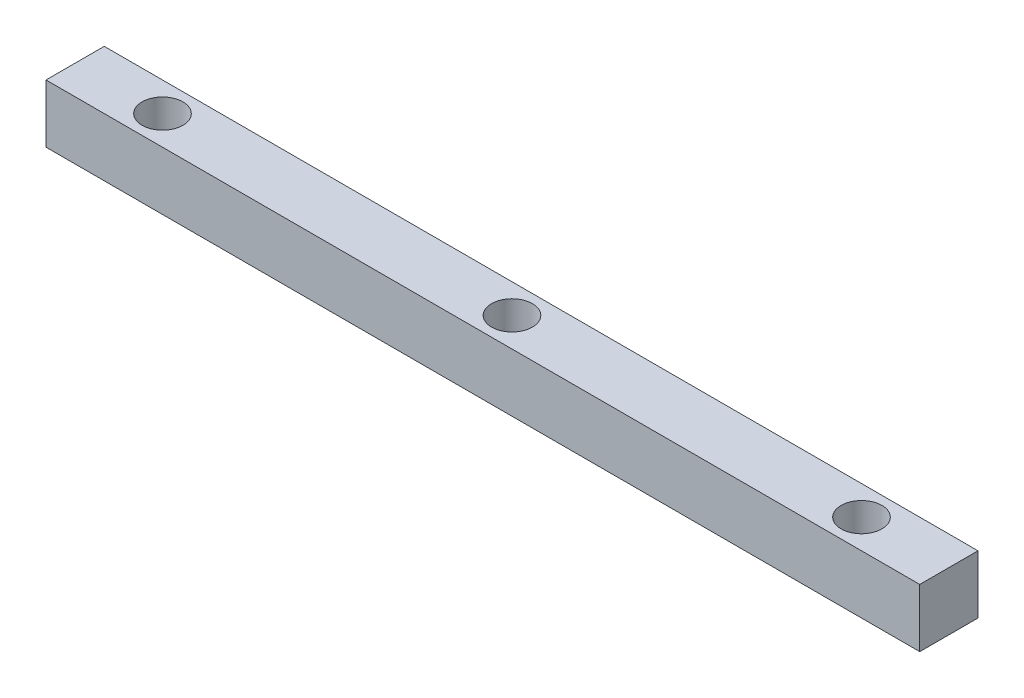
from build123d import *

# Parameters (mm, degrees)
SKETCH1_W           = 150
SKETCH1_H           = 10
BOSS_EXTRUDE1_DEPTH = 10
SKETCH2_R           = 3.5
CUT_EXTRUDE1_DEPTH  = 11


with BuildPart() as part:
    # Sketch1 → Boss-Extrude1 (new body)
    with BuildSketch(Plane(origin=(0, 0, 0), x_dir=(1, 0, 0), z_dir=(0, 1, 0))):
        with Locations((75, -5)):
            Rectangle(SKETCH1_W, SKETCH1_H)
    extrude(amount=BOSS_EXTRUDE1_DEPTH)

    # Sketch2 → Cut-Extrude1 (cut, through all)
    with BuildSketch(Plane(origin=(0, 10, 0), x_dir=(1, 0, 0), z_dir=(0, 1, 0))):
        with Locations(Location((15, -5, 0), (0, 0, 270))):  # turned: the seam where the file's is
            Circle(SKETCH2_R)
        with Locations(Location((75, -5, 0), (0, 0, 270))):  # turned: the seam where the file's is
            Circle(SKETCH2_R)
        with Locations(Location((135, -5, 0), (0, 0, 270))):  # turned: the seam where the file's is
            Circle(SKETCH2_R)
    extrude(amount=-CUT_EXTRUDE1_DEPTH, mode=Mode.SUBTRACT)


solid = part.part
